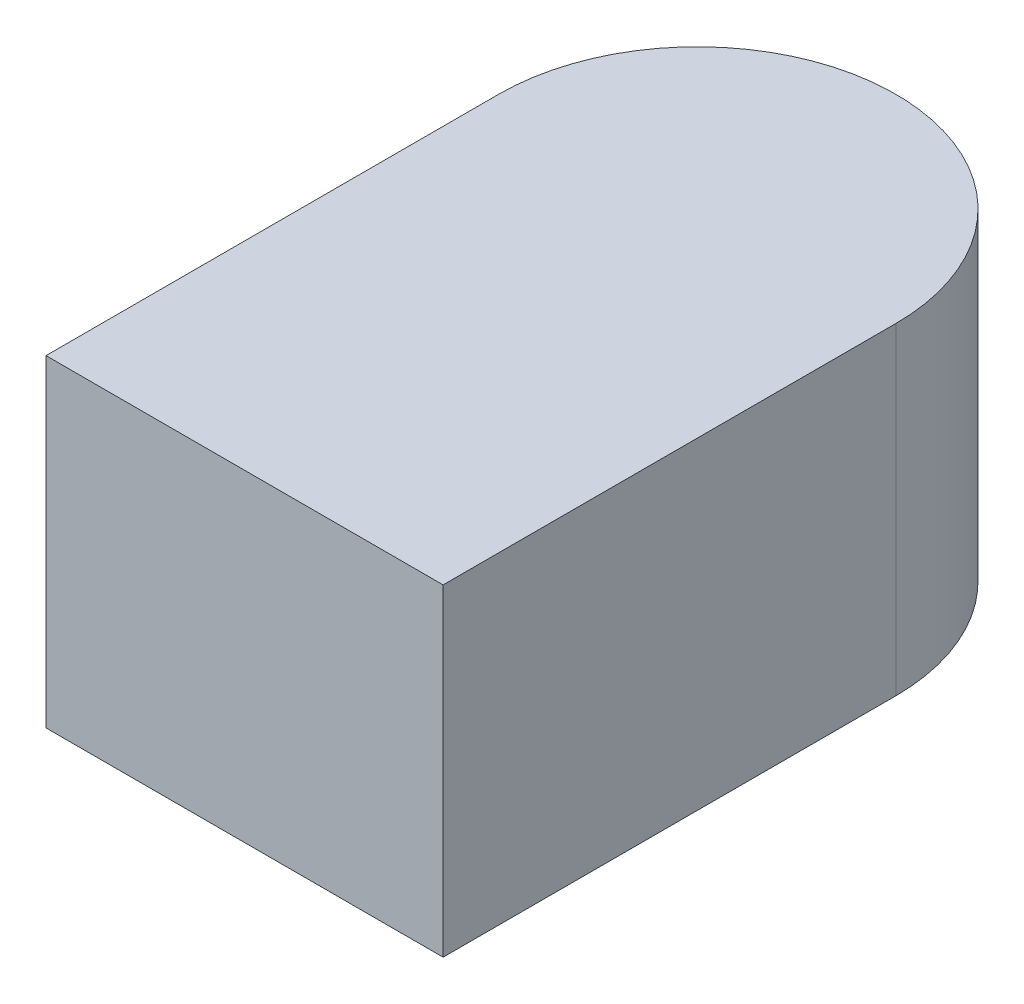
from build123d import *

# Parameters (mm, degrees)
BOSS_EXTRUDE1_DEPTH = 0.203


with BuildPart() as part:
    # Sketch1 → Boss-Extrude1 (new body)
    with BuildSketch(Plane(origin=(0, 0, 0), x_dir=(1, 0, 0), z_dir=(0, 1, 0))):
        with BuildLine():
            Line((-0.125, 0.1425), (-0.125, -0.1425))
            Line((-0.125, -0.1425), (0.125, -0.1425))
            Line((0.125, -0.1425), (0.125, 0.1425))
            ThreePointArc((0.125, 0.1425), (0, 0.2675), (-0.125, 0.1425))
        make_face()
    extrude(amount=BOSS_EXTRUDE1_DEPTH)


solid = part.part
